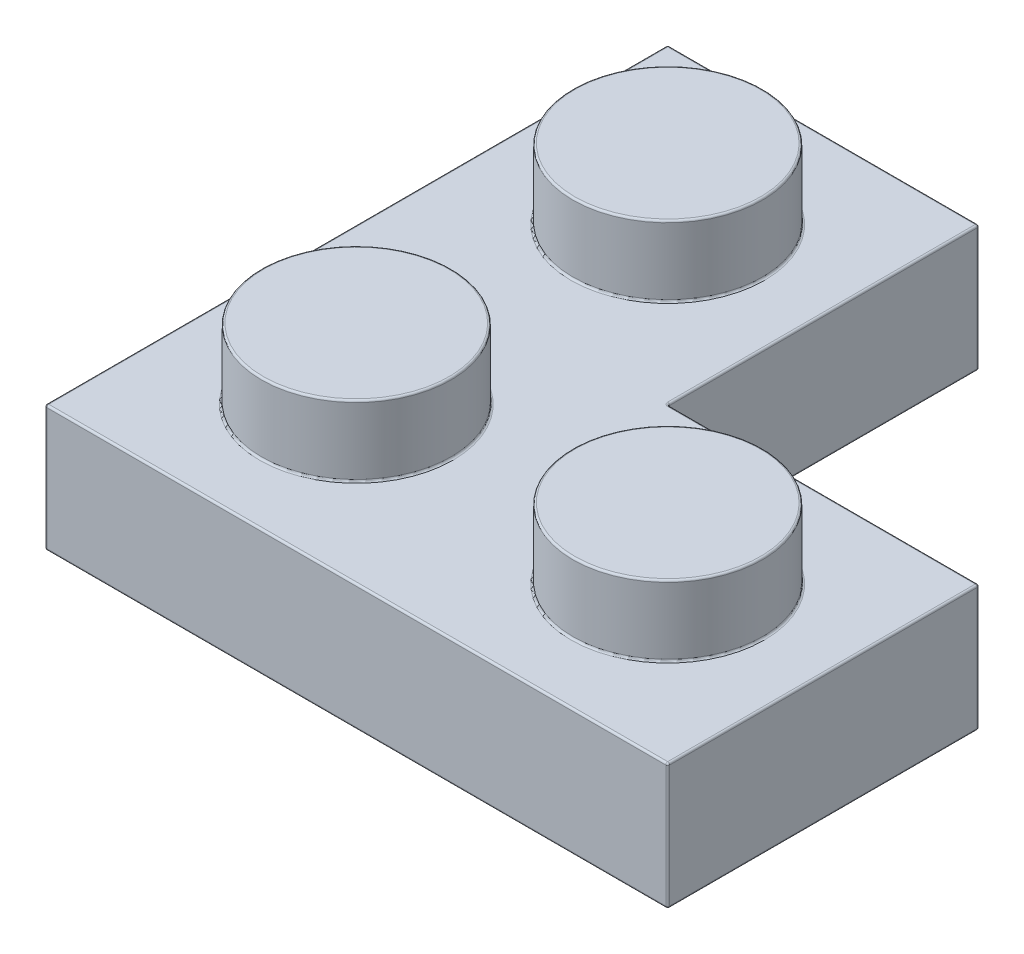
from build123d import *

# Parameters (mm, degrees)
SKETCH1_W       = 7.96
SKETCH1_H       = 7.96
EXTRUDE1_DEPTH  = 3.22
SKETCH2_R       = 2.425
EXTRUDE2_DEPTH  = 1.8
LPATTERN1_COUNT = 2
LPATTERN1_PITCH = 7.96
LPATTERN2_COUNT = 2
LPATTERN2_PITCH = 7.96
SHELL1_T        = -1.55
EXTRUDE3_DEPTH  = 0.14
SKETCH5_R       = 1.5
SKETCH5_R_2     = 0.64
EXTRUDE4_DEPTH  = 1.81
EXTRUDE5_DEPTH  = 1.81
FILLET1_R       = 0.05


with BuildPart() as part:
    # Sketch1 → Extrude1 (new body)
    with BuildSketch(Plane(origin=(0, 0, 0), x_dir=(1, 0, 0), z_dir=(0, 1, 0))):
        Rectangle(SKETCH1_W, SKETCH1_H)
    extrude1 = extrude(amount=EXTRUDE1_DEPTH)

    # Sketch2 → Extrude2 (add)
    with BuildSketch(Plane(origin=(0, 3.22, 0), x_dir=(1, 0, 0), z_dir=(0, 1, 0))):
        Circle(SKETCH2_R)
    extrude2 = extrude(amount=EXTRUDE2_DEPTH)

    # LPattern1: Extrude1, Extrude2 ×2
    with Locations(*[(i * LPATTERN1_PITCH, 0, 0) for i in range(1, LPATTERN1_COUNT)]):
        add(extrude1)
        add(extrude2)

    # LPattern2: Extrude1, Extrude2 ×2
    with Locations(*[(0, 0, -i * LPATTERN2_PITCH) for i in range(1, LPATTERN2_COUNT)]):
        add(extrude1)
        add(extrude2)

    # Shell1
    shell1_openings = [part.faces().sort_by_distance(p)[0] for p in [
        (4.643333333, 0, -3.316666667),
    ]]
    offset(amount=SHELL1_T, openings=shell1_openings, kind=Kind.INTERSECTION)

    # Sketch4 → Extrude3 (cut)
    with BuildSketch(Plane.XZ.offset(-1.67)):
        Polygon((2.43, -10.39), (-2.43, -10.39), (-2.43, 2.43), (10.39, 2.43), (10.39, -2.43), (2.43, -2.43), align=None)
    extrude(amount=-EXTRUDE3_DEPTH, mode=Mode.SUBTRACT)

    # Sketch5 → Extrude4 (add)
    with BuildSketch(Plane.XZ.offset(-1.81)):
        with Locations((0, -3.98)):
            Circle(SKETCH5_R)
        with Locations((0, -3.98)):
            Circle(SKETCH5_R_2, mode=Mode.SUBTRACT)
        with Locations((3.98, 0)):
            Circle(SKETCH5_R)
        with Locations((3.98, 0)):
            Circle(SKETCH5_R_2, mode=Mode.SUBTRACT)
    extrude(amount=EXTRUDE4_DEPTH)

    # Sketch6 → Extrude5 (add)
    with BuildSketch(Plane.XZ.offset(-1.81)):
        Polygon((2.43, -3.179533188), (1.454192642, -2.20372583), (2.20372583, -1.454192642), (3.179533188, -2.43), (2.43, -2.43), align=None)
    extrude(amount=EXTRUDE5_DEPTH)

    # Fillet1
    fillet1_edges = [part.edges().sort_by_distance(p)[0] for p in [
        (-3.98, 3.22, -3.98),
        (2.48, 1.81, 0),
        (3.34, 1.81, 0),
        (2.48, 0, 0),
        (3.34, 0, 0),
        (2.43, 0, -6.784766594),
        (6.784766594, 1.81, -2.43),
        (1.942096321, 0, -2.691629509),
        (1.454192642, 0.905, -2.20372583),
        (1.942096321, 1.81, -2.691629509),
        (1.828959236, 0, -1.828959236),
        (2.20372583, 0.905, -1.454192642),
        (1.828959236, 1.81, -1.828959236),
        (2.691629509, 0, -1.942096321),
        (3.179533188, 0.905, -2.43),
        (2.691629509, 1.81, -1.942096321),
        (2.43, 0.905, -3.179533188),
        (3.98, 3.22, 3.98),
        (-2.425, 3.22, 0),
        (-2.425, 5.02, 0),
        (11.94, 0, 0),
        (11.94, 1.61, 3.98),
        (11.94, 1.61, -3.98),
        (11.94, 3.22, 0),
        (5.535, 3.22, 0),
        (5.535, 5.02, 0),
        (3.98, 0, -7.96),
        (3.98, 1.61, -3.98),
        (0, 0, -11.94),
        (3.98, 1.61, -11.94),
        (-3.98, 1.61, -11.94),
        (3.98, 3.22, -7.96),
        (0, 3.22, -11.94),
        (3.98, 0, 3.98),
        (-2.425, 3.22, -7.96),
        (-2.425, 5.02, -7.96),
        (-3.98, 0, -3.98),
        (10.39, 0.905, -2.43),
        (6.784766594, 0, -2.43),
        (-2.43, 0, -3.98),
        (-2.43, 0.905, -10.39),
        (3.98, 0, 2.43),
        (-2.43, 0.905, 2.43),
        (7.96, 0, -3.98),
        (-0.875, 3.47, 0),
        (10.39, 0, 0),
        (10.39, 0.905, 2.43),
        (7.085, 3.47, 0),
        (0, 0, -10.39),
        (2.43, 0.905, -10.39),
        (-0.875, 3.47, -7.96),
        (7.96, 3.22, -3.98),
        (-0.875, 1.81, 0),
        (7.085, 1.81, 0),
        (-0.875, 1.81, -7.96),
        (2.43, 1.81, -6.784766594),
        (0, 1.81, -10.39),
        (-2.43, 1.81, -3.98),
        (3.98, 1.81, 2.43),
        (10.39, 1.81, 0),
        (-3.98, 1.61, 3.98),
        (-1.5, 1.81, -3.98),
        (-0.64, 1.81, -3.98),
        (-1.5, 0, -3.98),
        (-0.64, 0, -3.98),
    ]]
    fillet(fillet1_edges, radius=FILLET1_R)


solid = part.part
